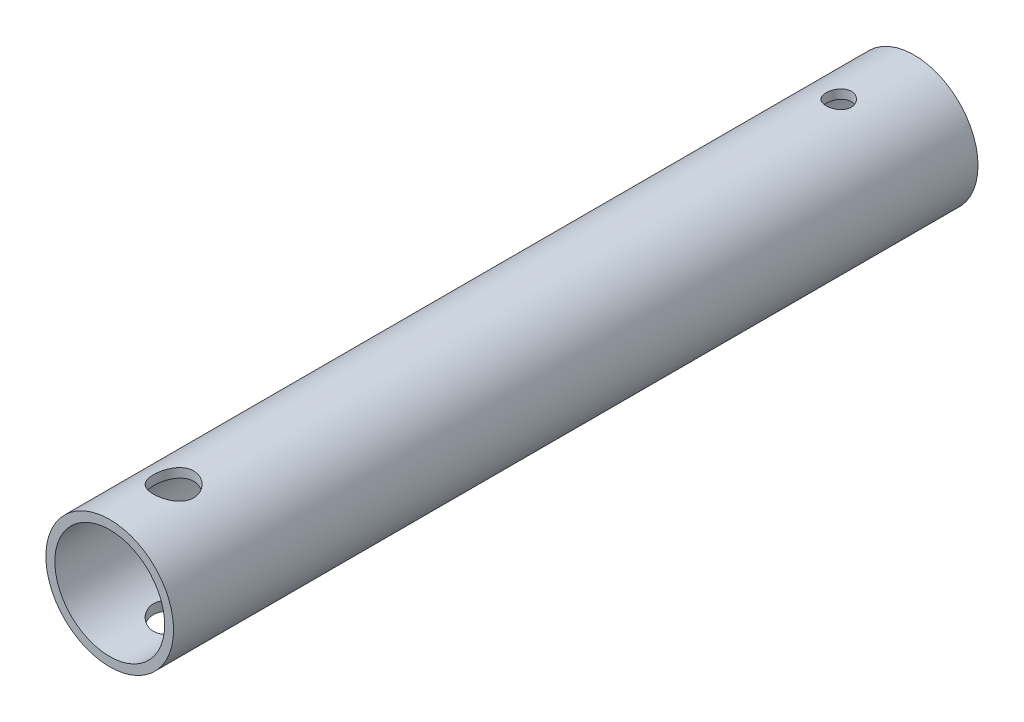
from build123d import *

# Parameters (mm, degrees)
SKETCH1_R               = 6.35
SKETCH1_R_2             = 5.461
EXTRUDE1_DEPTH          = 80
CUT_EXTRUDE1_DEPTH      = 38.1
CUT_EXTRUDE1_DEPTH_BACK = 38.1
SKETCH2_R               = 1.25
SKETCH2_R_2             = 2


with BuildPart() as part:
    # Sketch1 → Extrude1 (new body)
    with BuildSketch(Plane.XY):
        Circle(SKETCH1_R)
        Circle(SKETCH1_R_2, mode=Mode.SUBTRACT)
    extrude(amount=EXTRUDE1_DEPTH)

    # Sketch2 → Cut-Extrude1 (cut, two sides: drawn at the far end of the back side and taken through both)
    with BuildSketch(Plane(origin=(0, 0, 0), x_dir=(1, 0, 0), z_dir=(0, 1, 0)).offset(-CUT_EXTRUDE1_DEPTH_BACK)):
        with Locations((0, -7.5)):
            Circle(SKETCH2_R)
        with Locations((0, -73.65)):
            Circle(SKETCH2_R_2)
    extrude(amount=CUT_EXTRUDE1_DEPTH + CUT_EXTRUDE1_DEPTH_BACK, mode=Mode.SUBTRACT)


solid = part.part
